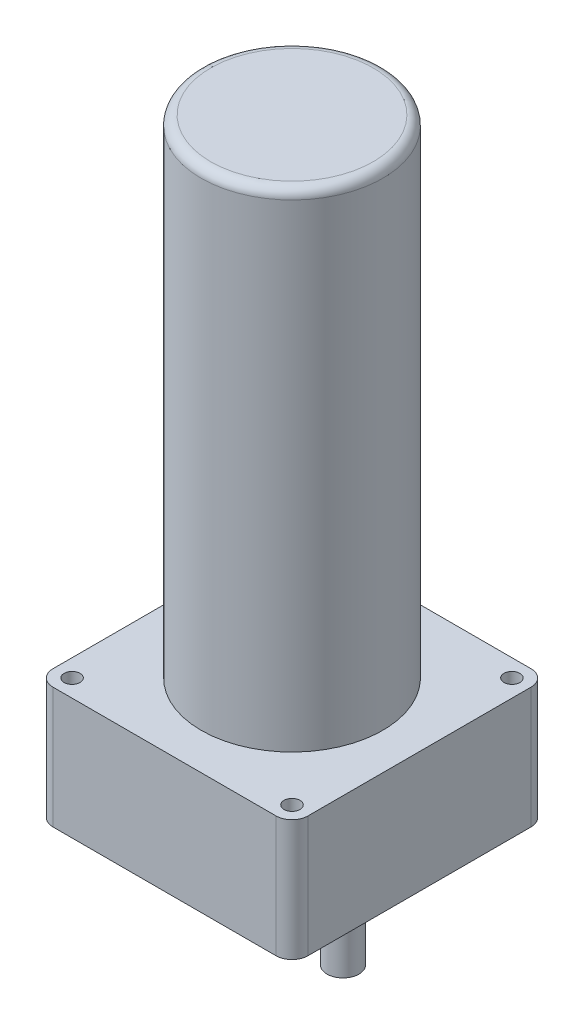
from build123d import *

# Parameters (mm, degrees)
SKETCH1_W           = 80
SKETCH1_H           = 80
BOSS_EXTRUDE1_DEPTH = 38
SKETCH2_R           = 28.5
BOSS_EXTRUDE2_DEPTH = 153
SKETCH3_R           = 36.5
CUT_EXTRUDE1_DEPTH  = 1
SKETCH4_R           = 15
BOSS_EXTRUDE3_DEPTH = 4
SKETCH5_R           = 5
BOSS_EXTRUDE4_DEPTH = 29
FILLET1_R           = 5
SKETCH6_R           = 2.5
CUT_EXTRUDE2_DEPTH  = 38
SKETCH7_R           = 2.5
CUT_EXTRUDE3_DEPTH  = 38
FILLET2_R           = 3


with BuildPart() as part:
    # Sketch1 → Boss-Extrude1 (new body)
    with BuildSketch(Plane(origin=(0, 0, 0), x_dir=(1, 0, 0), z_dir=(0, 1, 0))):
        Rectangle(SKETCH1_W, SKETCH1_H)
    extrude(amount=BOSS_EXTRUDE1_DEPTH)

    # Sketch2 → Boss-Extrude2 (add)
    with BuildSketch(Plane(origin=(0, 38, 0), x_dir=(1, 0, 0), z_dir=(0, 1, 0))):
        Circle(SKETCH2_R)
    extrude(amount=BOSS_EXTRUDE2_DEPTH)

    # Sketch3 → Cut-Extrude1 (cut)
    with BuildSketch(Plane.XZ):
        Circle(SKETCH3_R)
    extrude(amount=-CUT_EXTRUDE1_DEPTH, mode=Mode.SUBTRACT)

    # Sketch4 → Boss-Extrude3 (add)
    with BuildSketch(Plane.XZ.offset(-1)):
        with Locations((16, 0)):
            Circle(SKETCH4_R)
    extrude(amount=BOSS_EXTRUDE3_DEPTH)

    # Sketch5 → Boss-Extrude4 (add)
    with BuildSketch(Plane.XZ.offset(3)):
        with Locations((16, 0)):
            Circle(SKETCH5_R)
    extrude(amount=BOSS_EXTRUDE4_DEPTH)

    # Fillet1
    fillet1_edges = [part.edges().sort_by_distance(p)[0] for p in [
        (40, 19, 40),
        (-40, 19, 40),
        (-40, 19, -40),
        (40, 19, -40),
    ]]
    fillet(fillet1_edges, radius=FILLET1_R)

    # Sketch6 → Cut-Extrude2 (cut)
    with BuildSketch(Plane.XZ):
        with Locations((-34.5, 34.5)):
            Circle(SKETCH6_R)
    extrude(amount=-CUT_EXTRUDE2_DEPTH, mode=Mode.SUBTRACT)

    # Sketch7 → Cut-Extrude3 (cut)
    with BuildSketch(Plane.XZ):
        with Locations((34.5, 34.5)):
            Circle(SKETCH7_R)
        with Locations((34.5, -34.5)):
            Circle(SKETCH7_R)
        with Locations((-34.5, -34.5)):
            Circle(SKETCH7_R)
    extrude(amount=-CUT_EXTRUDE3_DEPTH, mode=Mode.SUBTRACT)

    # Fillet2
    fillet2_edges = [part.edges().sort_by_distance(p)[0] for p in [
        (-28.5, 191, 0),
    ]]
    fillet(fillet2_edges, radius=FILLET2_R)


solid = part.part
